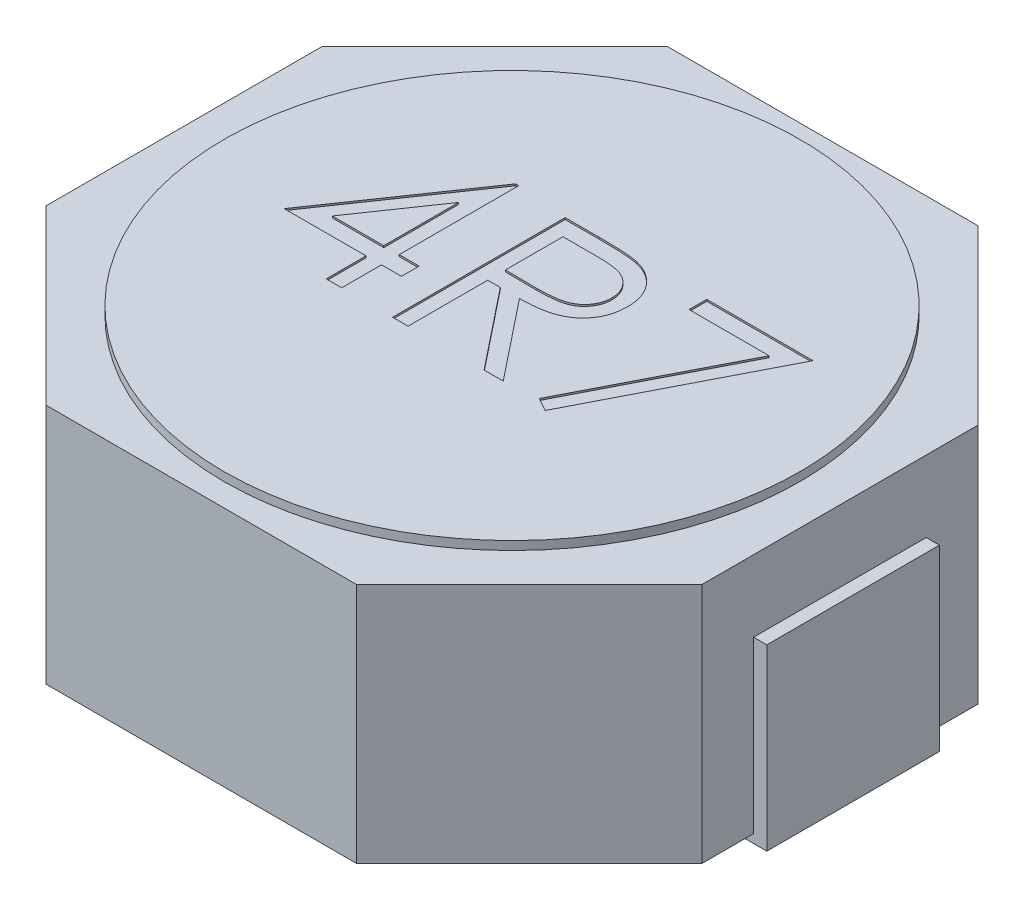
from build123d import *

# Parameters (mm, degrees)
BOSS_EXTRUDE1_DEPTH = 1.4
SKETCH2_R           = 1.667945685
BOSS_EXTRUDE2_DEPTH = 0.05
EXTRUDE_THIN1_DEPTH = 0.5
CUT_EXTRUDE1_DEPTH  = 0.01


with BuildPart() as part:
    # Sketch1 → Boss-Extrude1 (new body)
    with BuildSketch(Plane(origin=(0, 0, 0), x_dir=(1, 0, 0), z_dir=(0, 1, 0))):
        Polygon((-0.9, 1.8), (-1.9, 0.8), (-1.9, -0.8), (-0.9, -1.8), (0.9, -1.8), (1.9, -0.8), (1.9, 0.8), (0.9, 1.8), align=None)
    extrude(amount=BOSS_EXTRUDE1_DEPTH)

    # Sketch2 → Boss-Extrude2 (add)
    with BuildSketch(Plane(origin=(0, 1.4, 0), x_dir=(1, 0, 0), z_dir=(0, 1, 0))):
        Circle(SKETCH2_R)
    extrude(amount=BOSS_EXTRUDE2_DEPTH)

    # Sketch3 → Extrude-Thin1 (add, symmetric)
    with BuildSketch(Plane.XY):
        Polygon((-1.976364114, 0.98571962), (-1.976364114, -0.049866004), (-1.250724891, -0.049866004), (-1.250724891, 0.050133996), (-1.876364114, 0.050133996), (-1.876364114, 0.98571962), align=None)
    extrude_thin1 = extrude(amount=EXTRUDE_THIN1_DEPTH, both=True)

    # Mirror1: Extrude-Thin1 across plane
    add(extrude_thin1.mirror(Plane(origin=(0, 0, 0), x_dir=(0, 0, 1), z_dir=(1, 0, 0))))

    # Sketch4 → Cut-Extrude1 (cut)
    with BuildSketch(Plane(origin=(0, 1.45, 0), x_dir=(1, 0, 0), z_dir=(0, 1, 0))):
        Polygon((-0.600359123, 0.621056828), (-0.582129956, 0.621056828), (-0.582129956, -0.071250864), (-0.466745341, -0.071250864), (-0.466745341, -0.173814967), (-0.582129956, -0.173814967), (-0.582129956, -0.404584198), (-0.671873546, -0.404584198), (-0.671873546, -0.173814967), (-1.146232521, -0.173814967), align=None)
        Polygon((-0.671873546, -0.071250864), (-0.671873546, 0.363044008), (-0.969950469, -0.071250864), align=None, mode=Mode.SUBTRACT)
        with BuildLine():
            Line((-0.287258162, 0.595415802), (-0.087137969, 0.595415802))
            add(Edge.make_bspline(
                [(-0.087137969, 0.595415802), (-0.073783361, 0.595371349), (-0.048141034, 0.595285994), (-0.011405814, 0.594810062), (0.021973357, 0.593445961), (0.051979025, 0.59227208), (0.078610641, 0.590131525), (0.101949867, 0.588085626), (0.121889209, 0.585407437), (0.133959452, 0.582920173), (0.139424531, 0.581794008)],
                knots=[0, 0, 0, 0, 4.0065e-05, 7.6928e-05, 0.000110203, 0.000140284, 0.000167002, 0.000190343, 0.000210571, 0.000227307, 0.000227307, 0.000227307, 0.000227307], degree=3))
            add(Edge.make_bspline(
                [(0.139424531, 0.581794008), (0.146740709, 0.57998636), (0.161216992, 0.576409628), (0.182059868, 0.568849742), (0.201921103, 0.560101278), (0.220718196, 0.549825929), (0.238356993, 0.537947421), (0.255019368, 0.524670814), (0.270780929, 0.510068755), (0.285004252, 0.493773086), (0.298415409, 0.476676941), (0.309726446, 0.458190153), (0.319476868, 0.438858288), (0.327239873, 0.41848474), (0.333490723, 0.397267091), (0.33789822, 0.375013149), (0.340541416, 0.351824299), (0.340810518, 0.336007754), (0.340946967, 0.327987918)],
                knots=[0, 0, 0, 0, 2.2595e-05, 4.4707e-05, 6.6409e-05, 8.7656e-05, 0.00010888, 0.000130123, 0.000151523, 0.000173233, 0.000194949, 0.000216629, 0.000238129, 0.000259818, 0.000281941, 0.000304413, 0.000327795, 0.000351847, 0.000351847, 0.000351847, 0.000351847], degree=3))
            add(Edge.make_bspline(
                [(0.340946967, 0.327987918), (0.340527253, 0.314663602), (0.339708283, 0.288664411), (0.332072539, 0.250932731), (0.319564962, 0.215735784), (0.302329736, 0.183117887), (0.280381315, 0.153714846), (0.254002803, 0.127889002), (0.223179485, 0.106277598), (0.194485395, 0.091291082), (0.169138481, 0.081693108), (0.14827182, 0.074939863), (0.125509827, 0.069722159), (0.101070588, 0.065047835), (0.074852401, 0.06151878), (0.046918104, 0.058934039), (0.017247775, 0.057318596), (-0.003134816, 0.057078023), (-0.013620341, 0.056954264)],
                knots=[0, 0, 0, 0, 3.9936e-05, 7.7926e-05, 0.000114928, 0.000151669, 0.000188168, 0.000224574, 0.000261926, 0.000300721, 0.00032133, 0.000343187, 0.000366461, 0.00039133, 0.000417819, 0.000445785, 0.000475476, 0.000506932, 0.000506932, 0.000506932, 0.000506932], degree=3))
            Line((-0.013620341, 0.056954264), (0.353767479, -0.404584198))
            Line((0.353767479, -0.404584198), (0.242789915, -0.404584198))
            Line((0.242789915, -0.404584198), (-0.124597905, 0.056954264))
            Line((-0.124597905, 0.056954264), (-0.197514572, 0.056954264))
            Line((-0.197514572, 0.056954264), (-0.197514572, -0.404584198))
            Line((-0.197514572, -0.404584198), (-0.287258162, -0.404584198))
            Line((-0.287258162, -0.404584198), (-0.287258162, 0.595415802))
        make_face()
        with BuildLine():
            Line((-0.197514572, 0.4928517), (-0.197514572, 0.159518367))
            Line((-0.197514572, 0.159518367), (-0.014421623, 0.158116123))
            add(Edge.make_bspline(
                [(-0.014421623, 0.158116123), (-0.005873041, 0.158112341), (0.010696547, 0.158105011), (0.034668166, 0.15924609), (0.056988198, 0.160544181), (0.07757127, 0.162529708), (0.096426577, 0.165088585), (0.113544695, 0.168289438), (0.128953567, 0.172018599), (0.146924578, 0.177790492), (0.166992158, 0.186935069), (0.188801147, 0.200239497), (0.207373243, 0.216973531), (0.223064061, 0.236108804), (0.23567247, 0.257147732), (0.244561629, 0.279838123), (0.250202326, 0.303607151), (0.250867625, 0.319943754), (0.251203377, 0.328188238)],
                knots=[0, 0, 0, 0, 2.5642e-05, 4.9701e-05, 7.1981e-05, 9.2711e-05, 0.00011172, 0.000129047, 0.000144934, 0.000159251, 0.000185611, 0.000210901, 0.000235588, 0.000260211, 0.000284912, 0.000308831, 0.00033308, 0.000357785, 0.000357785, 0.000357785, 0.000357785], degree=3))
            add(Edge.make_bspline(
                [(0.251203377, 0.328188238), (0.250859914, 0.336230117), (0.250179295, 0.352166185), (0.244622504, 0.375496445), (0.235225538, 0.397515573), (0.222562041, 0.418133998), (0.207133711, 0.436849922), (0.189042908, 0.452863395), (0.168784281, 0.466077527), (0.149849653, 0.474521636), (0.132925592, 0.479698737), (0.118231403, 0.483341927), (0.101628124, 0.486268918), (0.083035136, 0.488614078), (0.062531813, 0.490629776), (0.040014484, 0.491987427), (0.015632547, 0.492791389), (-0.001266577, 0.492831128), (-0.010014572, 0.4928517)],
                knots=[0, 0, 0, 0, 2.4106e-05, 4.7769e-05, 7.1469e-05, 9.5656e-05, 0.000120124, 0.000143963, 0.000167855, 0.000192425, 0.000205857, 0.000220919, 0.000237814, 0.0002564, 0.00027713, 0.00029961, 0.000324062, 0.000350305, 0.000350305, 0.000350305, 0.000350305], degree=3))
            Line((-0.010014572, 0.4928517), (-0.197514572, 0.4928517))
        make_face(mode=Mode.SUBTRACT)
        Polygon((0.533254659, 0.595415802), (1.148639274, 0.595415802), (0.622998249, -0.430225223), (0.54547421, -0.387556954), (0.996796326, 0.4928517), (0.533254659, 0.4928517), align=None)
    extrude(amount=-CUT_EXTRUDE1_DEPTH, mode=Mode.SUBTRACT)


solid = part.part
